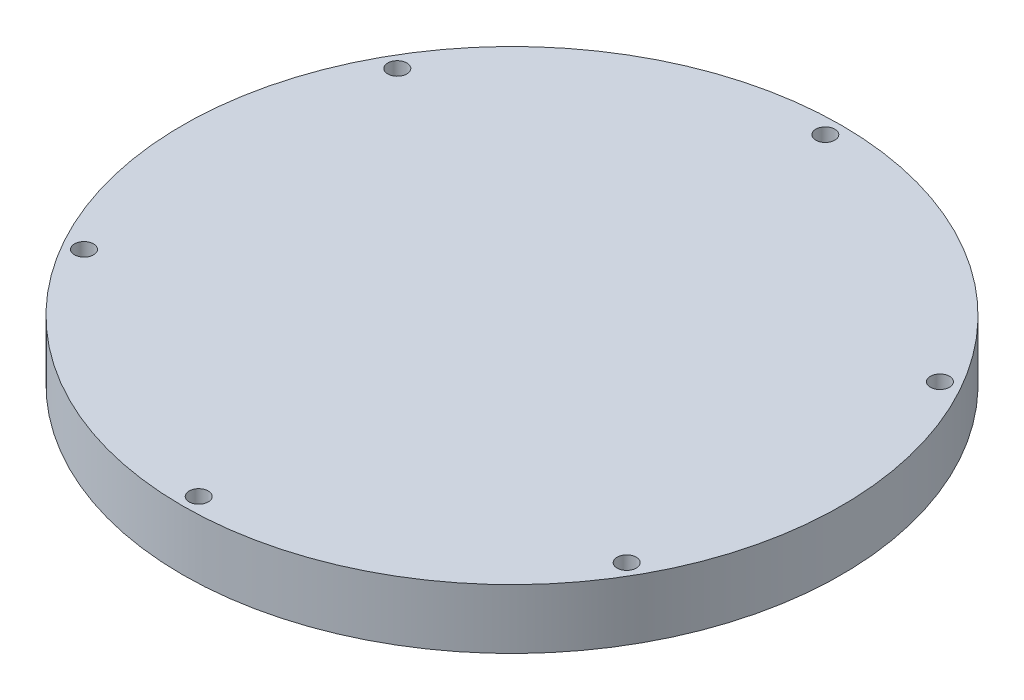
from build123d import *

# Parameters (mm, degrees)
SKETCH_1_R              = 55.25
EXTRUDE_1_DEPTH         = 10
HOLE_WIZARD_3_2_3_2_1_D = 3.2


with BuildPart() as part:
    # 草图1 → 凸台-拉伸1 (new body)
    with BuildSketch(Plane(origin=(0, 0, 0), x_dir=(1, 0, 0), z_dir=(0, 1, 0))):
        Circle(SKETCH_1_R)
    extrude(amount=EXTRUDE_1_DEPTH)

    # Ø3.2 (3.2) 直径孔1 (through all)
    with Locations(Plane(origin=(0, 10, -52.525), x_dir=(0, 0, 1), z_dir=(0, 1, 0))):
        with Locations((0, 0), (26.2625, -45.487984334), (78.7875, -45.487984334), (105.05, 0), (78.7875, 45.487984334), (26.2625, 45.487984334)):
            Hole(HOLE_WIZARD_3_2_3_2_1_D / 2)


solid = part.part
